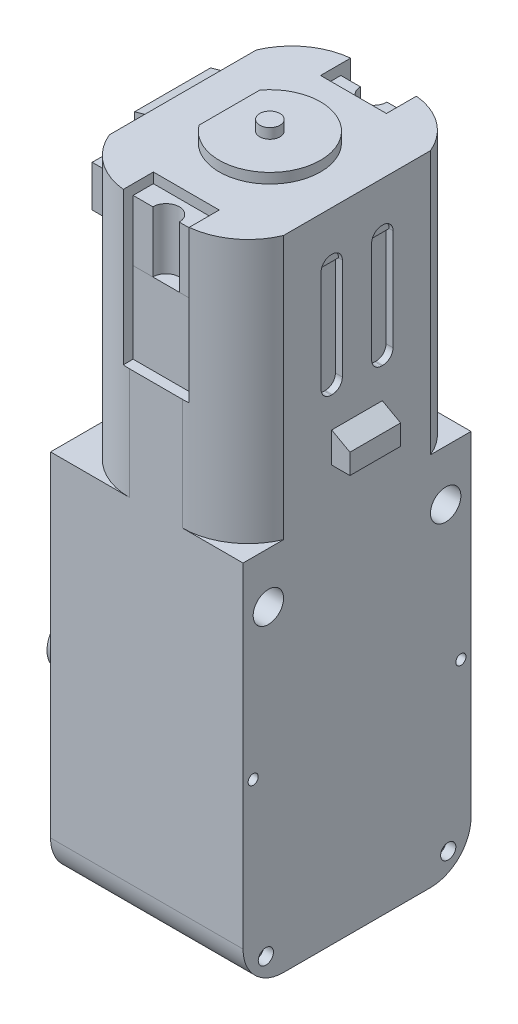
from build123d import *

# Parameters (mm, degrees)
SALIENTE_EXTRUIR2_DEPTH       = 9.5
SALIENTE_EXTRUIR2_DEPTH_BACK  = 9.5
SALIENTE_EXTRUIR4_DEPTH       = 1.3
SALIENTE_EXTRUIR4_DEPTH_BACK  = 1.3
CROQUIS2_R                    = 1.5
CROQUIS3_R                    = 2.5
CORTAR_EXTRUIR1_DEPTH         = 5
CROQUIS5_R                    = 0.75
CROQUIS5_R_2                  = 0.5
CORTAR_EXTRUIR2_DEPTH         = 1
CORTAR_EXTRUIR3_START         = -1
CROQUIS4_R                    = 0.5
CROQUIS4_R_2                  = 0.75
CORTAR_EXTRUIR3_DEPTH         = 1
CROQUIS6_R                    = 2
SALIENTE_EXTRUIR6_DEPTH       = 2
CROQUIS7_R                    = 1.5
CORTAR_EXTRUIR4_DEPTH         = 37.97672376
SALIENTE_EXTRUIR7_DEPTH       = 26
CROQUIS9_W                    = 27.483780483
CROQUIS9_H                    = 31.518144496
CORTAR_EXTRUIR5_DEPTH         = 60.879863894
CORTAR_EXTRUIR7_DEPTH         = 60.879863894
CORTAR_EXTRUIR7_DEPTH_BACK    = 60.879863894
CROQUIS11_W                   = 28.397068188
CROQUIS11_H                   = 15.296763251
CROQUIS12_W                   = 23.354698513
CROQUIS12_H                   = 7.169049234
CROQUIS12_R                   = 1.5
CORTAR_EXTRUIR8_DEPTH         = 60.879863894
CROQUIS14_W                   = 19
CROQUIS14_H                   = 22.5
SALIENTE_EXTRUIR9_DEPTH       = 30
CROQUIS15_R                   = 1.5
CORTAR_EXTRUIR9_DEPTH         = 60.879863894
CROQUIS16_R                   = 2
SALIENTE_EXTRUIR10_DEPTH      = 2
CROQUIS17_R                   = 0.5
CROQUIS17_R_2                 = 0.75
CORTAR_EXTRUIR10_DEPTH        = 60.879863894
CROQUIS20_W                   = 0.773109855
CROQUIS20_H                   = 0.470542453
SALIENTE_EXTRUIR12_DEPTH      = 24
CROQUIS21_W                   = 16.85701041
CROQUIS21_H                   = 22.5
SALIENTE_EXTRUIR13_DEPTH      = 24
CORTAR_EXTRUIR11_DEPTH        = 60.879863894
CROQUIS22_R                   = 2.6
CORTAR_EXTRUIR12_DEPTH        = 5
CROQUIS23_R                   = 2.75
CROQUIS23_R_2                 = 2.6
SALIENTE_EXTRUIR14_DEPTH      = 0.5
SALIENTE_EXTRUIR14_DRAFT      = 8
CROQUIS24_W                   = 2.5
CROQUIS24_H                   = 5
SALIENTE_EXTRUIR15_DEPTH      = 4.7
CROQUIS25_R                   = 1.4
CORTAR_EXTRUIR13_DEPTH        = 4.7
SALIENTE_EXTRUIR17_DEPTH      = 2
SALIENTE_EXTRUIR17_DEPTH_BACK = 19
CROQUIS26_W                   = 3
CROQUIS26_H                   = 5
CORTAR_EXTRUIR14_DEPTH        = 58.938312885
CORTAR_EXTRUIR14_DEPTH_BACK   = 58.938312885
CORTAR_EXTRUIR15_DEPTH        = 60.879863894
CORTAR_EXTRUIR16_START        = -7
CORTAR_EXTRUIR16_DEPTH        = 7
SALIENTE_EXTRUIR18_DEPTH      = 3.75
SALIENTE_EXTRUIR18_DEPTH_BACK = 3.75
CROQUIS30_W                   = 7.5
CROQUIS30_H                   = 1
CORTAR_EXTRUIR17_DEPTH        = 58.938312885
CORTAR_EXTRUIR17_DEPTH_BACK   = 58.938312885
CROQUIS31_W                   = 5.5
CROQUIS31_H                   = 1.5
CORTAR_EXTRUIR18_DEPTH        = 58.938312885
CORTAR_EXTRUIR18_DEPTH_BACK   = 58.938312885
CORTAR_EXTRUIR22_DEPTH        = 59.781677417
CORTAR_EXTRUIR22_DEPTH_BACK   = 59.781677417
CORTAR_EXTRUIR23_START        = -15
CORTAR_EXTRUIR23_DEPTH        = 15
CORTAR_EXTRUIR24_DEPTH        = 5
CROQUIS37_W                   = 15.777972317
CROQUIS37_H                   = 14.808381702
SALIENTE_EXTRUIR19_DEPTH      = 11
CROQUIS38_W                   = 18.88083152
CROQUIS38_H                   = 4.081408477
SALIENTE_EXTRUIR21_DEPTH      = 1
CROQUIS39_W                   = 9.12350037
CROQUIS39_H                   = 4.081408477
SALIENTE_EXTRUIR23_DEPTH      = 0.6
CROQUIS40_W                   = 6.5
CROQUIS40_H                   = 2
SALIENTE_EXTRUIR24_DEPTH      = 8
SALIENTE_EXTRUIR24_2_DEPTH    = 8
CROQUIS41_R                   = 1
SALIENTE_EXTRUIR26_DEPTH      = 7
SALIENTE_EXTRUIR27_DEPTH      = 6
SALIENTE_EXTRUIR27_2_DEPTH    = 6
SALIENTE_EXTRUIR28_DEPTH      = 6
CROQUIS44_W                   = 5.21443522
CROQUIS44_H                   = 9.574781913
SALIENTE_EXTRUIR29_DEPTH      = 2
CROQUIS46_R                   = 0.697640257
SALIENTE_EXTRUIR32_DEPTH      = 0.4
SALIENTE_EXTRUIR32_2_DEPTH    = 0.4
CROQUIS47_R                   = 2.6
SALIENTE_EXTRUIR33_DEPTH      = 14
CORTAR_EXTRUIR25_DEPTH        = 8
CROQUIS49_R                   = 1
CORTAR_EXTRUIR26_DEPTH        = 8


with BuildPart() as part:
    # Croquis1 → Saliente-Extruir2 (new, two sides: drawn at the far end of the back side and taken through both)
    with BuildSketch(Plane.YZ.offset(-SALIENTE_EXTRUIR2_DEPTH_BACK)):
        with BuildLine():
            Line((29.66, 11.25), (-4.84, 11.25))
            ThreePointArc((-4.84, 11.25), (-6.607766953, 10.517766953), (-7.34, 8.75))
            Line((-7.34, 8.75), (-7.34, -8.75))
            ThreePointArc((-7.34, -8.75), (-6.607766953, -10.517766953), (-4.84, -11.25))
            Line((-4.84, -11.25), (29.66, -11.25))
            Line((29.66, -11.25), (29.66, 11.25))
        make_face()
    extrude(amount=SALIENTE_EXTRUIR2_DEPTH + SALIENTE_EXTRUIR2_DEPTH_BACK)

    # Croquis2 → Saliente-Extruir4 (add, two sides: drawn at the far end of the back side and taken through both)
    with BuildSketch(Plane.YZ.offset(-SALIENTE_EXTRUIR4_DEPTH_BACK)):
        Polygon((-11.84, -1.34), (-11.84, -2.5), (-7.34, -2.5), (-7.34, 2.5), (-11.84, 2.5), (-11.84, 1.34), (-11.84, 0), align=None)
        with Locations((-9.34, 0)):
            Circle(CROQUIS2_R, mode=Mode.SUBTRACT)
    extrude(amount=SALIENTE_EXTRUIR4_DEPTH + SALIENTE_EXTRUIR4_DEPTH_BACK)

    # Croquis3 → Cortar-Extruir1 (cut)
    with BuildSketch(Plane(origin=(-9.5, 0, 0), x_dir=(0, -1, 0), z_dir=(-1, 0, 0))):
        Circle(CROQUIS3_R)
    extrude(amount=-CORTAR_EXTRUIR1_DEPTH, mode=Mode.SUBTRACT)

    # Croquis5 → Cortar-Extruir2 (cut)
    with BuildSketch(Plane.YZ.offset(9.5)):
        with Locations((-4.84, 8.75)):
            Circle(CROQUIS5_R)
        with Locations((5.66, 9.75)):
            Circle(CROQUIS5_R_2)
        with Locations((5.66, -9.75)):
            Circle(CROQUIS5_R_2)
        with Locations((-4.84, -8.75)):
            Circle(CROQUIS5_R)
    extrude(amount=-CORTAR_EXTRUIR2_DEPTH, mode=Mode.SUBTRACT)

    # Croquis4 → Cortar-Extruir3 (cut)
    with BuildSketch(Plane.ZY.offset(9.5).offset(CORTAR_EXTRUIR3_START)):
        with Locations((9.75, 5.66)):
            Circle(CROQUIS4_R)
        with Locations((8.75, -4.84)):
            Circle(CROQUIS4_R_2)
        with Locations((-9.75, 5.66)):
            Circle(CROQUIS4_R)
        with Locations((-8.75, -4.84)):
            Circle(CROQUIS4_R_2)
    extrude(amount=CORTAR_EXTRUIR3_DEPTH, mode=Mode.SUBTRACT)

    # Croquis6 → Saliente-Extruir6 (add)
    with BuildSketch(Plane.ZY.offset(9.5)):
        with Locations((0, 10.66)):
            Circle(CROQUIS6_R)
    extrude(amount=SALIENTE_EXTRUIR6_DEPTH)

    # Croquis7 → Cortar-Extruir4 (cut, through all)
    with BuildSketch(Plane.ZY.offset(9.5)):
        with Locations((-8.75, 19.66)):
            Circle(CROQUIS7_R)
        with Locations((8.75, 19.66)):
            Circle(CROQUIS7_R)
    extrude(amount=-CORTAR_EXTRUIR4_DEPTH, mode=Mode.SUBTRACT)

    # Croquis8 → Saliente-Extruir7 (add)
    with BuildSketch(Plane(origin=(0, 29.66, 0), x_dir=(-1, 0, 0), z_dir=(0, 1, 0))):
        with BuildLine():
            Line((1.7, 11.25), (-3.5, 11.25))
            ThreePointArc((-3.5, 11.25), (-7.105551275, 10.158326913), (-9.5, 7.25))
            Line((-9.5, 7.25), (-9.5, -7.25))
            ThreePointArc((-9.5, -7.25), (-7.105551275, -10.158326913), (-3.5, -11.25))
            Line((-3.5, -11.25), (1.7, -11.25))
            ThreePointArc((1.7, -11.25), (5.305551275, -10.158326913), (7.7, -7.25))
            Line((7.7, -7.25), (7.7, 7.25))
            ThreePointArc((7.7, 7.25), (5.305551275, 10.158326913), (1.7, 11.25))
        make_face()
    extrude(amount=SALIENTE_EXTRUIR7_DEPTH)

    # Croquis9 → Cortar-Extruir5 (cut, through all)
    with BuildSketch(Plane(origin=(-9.5, 0, 0), x_dir=(0, -1, 0), z_dir=(-1, 0, 0))):
        with Locations((5.081890242, -0.401551564)):
            Rectangle(CROQUIS9_W, CROQUIS9_H)
    extrude(amount=-CORTAR_EXTRUIR5_DEPTH, mode=Mode.SUBTRACT)

    # Croquis11 → Cortar-Extruir7 (cut, two sides: drawn at the far end of the back side and taken through both)
    with BuildSketch(Plane.ZY.offset(9.5).offset(-CORTAR_EXTRUIR7_DEPTH_BACK)):
        with Locations((-0.835139934, 10.44632309)):
            Rectangle(CROQUIS11_W, CROQUIS11_H)
    extrude(amount=CORTAR_EXTRUIR7_DEPTH + CORTAR_EXTRUIR7_DEPTH_BACK, mode=Mode.SUBTRACT)

    # Croquis12 → Cortar-Extruir8 (cut, through all)
    with BuildSketch(Plane.ZY.offset(9.5)):
        with Locations((0.427349257, 19.075475383)):
            Rectangle(CROQUIS12_W, CROQUIS12_H)
        with Locations((-8.75, 19.66)):
            Circle(CROQUIS12_R, mode=Mode.SUBTRACT)
        with Locations((8.75, 19.66)):
            Circle(CROQUIS12_R, mode=Mode.SUBTRACT)
    extrude(amount=-CORTAR_EXTRUIR8_DEPTH, mode=Mode.SUBTRACT)

    # Croquis14 → Saliente-Extruir9 (add)
    with BuildSketch(Plane(origin=(0, 22.66, 0), x_dir=(-1, 0, 0), z_dir=(0, -1, 0))):
        Rectangle(CROQUIS14_W, CROQUIS14_H)
    extrude(amount=SALIENTE_EXTRUIR9_DEPTH)

    # Croquis15 → Cortar-Extruir9 (cut, through all)
    with BuildSketch(Plane.ZY.offset(9.5)):
        with Locations((-8.75, 24.66)):
            Circle(CROQUIS15_R)
        with Locations((8.75, 24.66)):
            Circle(CROQUIS15_R)
    extrude(amount=-CORTAR_EXTRUIR9_DEPTH, mode=Mode.SUBTRACT)

    # Croquis16 → Saliente-Extruir10 (add)
    with BuildSketch(Plane.ZY.offset(9.5)):
        with Locations((0, 15.66)):
            Circle(CROQUIS16_R)
    extrude(amount=SALIENTE_EXTRUIR10_DEPTH)

    # Croquis17 → Cortar-Extruir10 (cut, through all)
    with BuildSketch(Plane.ZY.offset(9.5)):
        with Locations((10.25, 10.66)):
            Circle(CROQUIS17_R)
        with Locations((9, -5.09)):
            Circle(CROQUIS17_R_2)
        with Locations((-9, -5.09)):
            Circle(CROQUIS17_R_2)
        with Locations((-10.25, 10.66)):
            Circle(CROQUIS17_R)
    extrude(amount=-CORTAR_EXTRUIR10_DEPTH, mode=Mode.SUBTRACT)

    # Croquis20 → Saliente-Extruir12 (add)
    with BuildSketch(Plane.XZ.offset(7.34)):
        with Locations((2.429452283, 4.566914846)):
            Rectangle(CROQUIS20_W, CROQUIS20_H)
    extrude(amount=-SALIENTE_EXTRUIR12_DEPTH)

    # Croquis21 → Saliente-Extruir13 (add)
    with BuildSketch(Plane(origin=(0, -7.34, 0), x_dir=(-1, 0, 0), z_dir=(0, -1, 0))):
        with Locations((-0.10132468, 0)):
            Rectangle(CROQUIS21_W, CROQUIS21_H)
    extrude(amount=-SALIENTE_EXTRUIR13_DEPTH)

    # Croquis19 → Cortar-Extruir11 (cut, through all)
    with BuildSketch(Plane.ZY.offset(9.5)):
        with BuildLine():
            Line((7.25, -7.34), (11.25, -7.34))
            Line((11.25, -7.34), (11.25, -3.34))
            ThreePointArc((11.25, -3.34), (10.078427125, -6.168427125), (7.25, -7.34))
        make_face()
        with BuildLine():
            Line((-11.25, -7.34), (-7.25, -7.34))
            ThreePointArc((-7.25, -7.34), (-10.078427125, -6.168427125), (-11.25, -3.34))
            Line((-11.25, -3.34), (-11.25, -7.34))
        make_face()
    extrude(amount=-CORTAR_EXTRUIR11_DEPTH, mode=Mode.SUBTRACT)

    # Croquis22 → Cortar-Extruir12 (cut)
    with BuildSketch(Plane.ZY.offset(9.5)):
        with Locations((0, 3.86)):
            Circle(CROQUIS22_R)
    extrude(amount=-CORTAR_EXTRUIR12_DEPTH, mode=Mode.SUBTRACT)


with BuildPart() as saliente_extruir14_tool:
    # Croquis23 → Saliente-Extruir14 (with draft: the straight prism first)
    with BuildSketch(Plane.ZY.offset(9.5)):
        with Locations((0, 3.86)):
            Circle(CROQUIS23_R)
        with Locations((0, 3.86)):
            Circle(CROQUIS23_R_2, mode=Mode.SUBTRACT)
    extrude(amount=SALIENTE_EXTRUIR14_DEPTH)
    # Saliente-Extruir14: the draft: its side faces are tilted about the plane it starts from
    saliente_extruir14_sides = [saliente_extruir14_tool.faces().sort_by_distance(p)[0] for p in [
        (-9.75, 3.86, -2.75),
        (-9.75, 3.86, -2.6),
    ]]
    draft(saliente_extruir14_sides, Plane.ZY.offset(9.5), SALIENTE_EXTRUIR14_DRAFT)


with BuildPart() as part_1:
    add(part.part)

    # Saliente-Extruir14: add saliente_extruir14_tool
    add(saliente_extruir14_tool.part)

    # Croquis24 → Saliente-Extruir15 (add)
    with BuildSketch(Plane.XZ.offset(7.34)):
        Rectangle(CROQUIS24_W, CROQUIS24_H)
    extrude(amount=SALIENTE_EXTRUIR15_DEPTH)

    # Croquis25 → Cortar-Extruir13 (cut)
    with BuildSketch(Plane.ZY.offset(1.25)):
        with Locations((0, -9.64)):
            Circle(CROQUIS25_R)
    extrude(amount=-CORTAR_EXTRUIR13_DEPTH, mode=Mode.SUBTRACT)

    # Croquis26 → Saliente-Extruir17 (add, two sides: drawn at the far end of the back side and taken through both)
    with BuildSketch(Plane(origin=(-7.7, 0, 0), x_dir=(0, -1, 0), z_dir=(-1, 0, 0)).offset(-SALIENTE_EXTRUIR17_DEPTH_BACK)):
        with Locations((-35.16, 0)):
            Rectangle(CROQUIS26_W, CROQUIS26_H)
    extrude(amount=SALIENTE_EXTRUIR17_DEPTH + SALIENTE_EXTRUIR17_DEPTH_BACK)

    # Croquis27 → Cortar-Extruir14 (cut, two sides: drawn at the far end of the back side and taken through both)
    with BuildSketch(Plane(origin=(0, 0, 0), x_dir=(0, 1, 0), z_dir=(0, 0, 1)).offset(-CORTAR_EXTRUIR14_DEPTH_BACK)):
        Polygon((36.66, -9.5), (35.66, -11.3), (36.66, -11.3), align=None)
        Polygon((36.66, 9.7), (35.66, 9.7), (36.66, 7.7), align=None)
    extrude(amount=CORTAR_EXTRUIR14_DEPTH + CORTAR_EXTRUIR14_DEPTH_BACK, mode=Mode.SUBTRACT)

    # Croquis28 → Cortar-Extruir15 (cut, through all)
    with BuildSketch(Plane(origin=(-7.7, 0, 0), x_dir=(0, -1, 0), z_dir=(-1, 0, 0))):
        with BuildLine():
            Line((-40.66, -1.446465015), (-45.66, -1.446465015))
            ThreePointArc((-45.66, -1.446465015), (-46.367106781, -1.739358234), (-46.66, -2.446465015))
            Line((-46.66, -2.446465015), (-46.66, -2.553534985))
            ThreePointArc((-46.66, -2.553534985), (-46.367106781, -3.260641766), (-45.66, -3.553534985))
            Line((-45.66, -3.553534985), (-40.66, -3.553534985))
            ThreePointArc((-40.66, -3.553534985), (-39.952893219, -3.260641766), (-39.66, -2.553534985))
            Line((-39.66, -2.553534985), (-39.66, -2.446465015))
            ThreePointArc((-39.66, -2.446465015), (-39.952893219, -1.739358234), (-40.66, -1.446465015))
        make_face()
        with BuildLine():
            Line((-40.66, 3.553534985), (-45.66, 3.553534985))
            ThreePointArc((-45.66, 3.553534985), (-46.367106781, 3.260641766), (-46.66, 2.553534985))
            Line((-46.66, 2.553534985), (-46.66, 2.446465015))
            ThreePointArc((-46.66, 2.446465015), (-46.367106781, 1.739358234), (-45.66, 1.446465015))
            Line((-45.66, 1.446465015), (-40.66, 1.446465015))
            ThreePointArc((-40.66, 1.446465015), (-39.952893219, 1.739358234), (-39.66, 2.446465015))
            Line((-39.66, 2.446465015), (-39.66, 2.553534985))
            ThreePointArc((-39.66, 2.553534985), (-39.952893219, 3.260641766), (-40.66, 3.553534985))
        make_face()
    extrude(amount=-CORTAR_EXTRUIR15_DEPTH, mode=Mode.SUBTRACT)

    # Croquis29 → Cortar-Extruir16 (cut)
    with BuildSketch(Plane.YZ.offset(9.5).offset(CORTAR_EXTRUIR16_START)):
        with BuildLine():
            Line((50.66, -1.446465015), (45.66, -1.446465015))
            ThreePointArc((45.66, -1.446465015), (46.367106781, -1.739358234), (46.66, -2.446465015))
            Line((46.66, -2.446465015), (46.66, -2.553534985))
            ThreePointArc((46.66, -2.553534985), (46.367106781, -3.260641766), (45.66, -3.553534985))
            Line((45.66, -3.553534985), (50.66, -3.553534985))
            ThreePointArc((50.66, -3.553534985), (51.367106781, -3.260641766), (51.66, -2.553534985))
            Line((51.66, -2.553534985), (51.66, -2.446465015))
            ThreePointArc((51.66, -2.446465015), (51.367106781, -1.739358234), (50.66, -1.446465015))
        make_face()
        with BuildLine():
            Line((50.66, 3.553534985), (45.66, 3.553534985))
            ThreePointArc((45.66, 3.553534985), (46.367106781, 3.260641766), (46.66, 2.553534985))
            Line((46.66, 2.553534985), (46.66, 2.446465015))
            ThreePointArc((46.66, 2.446465015), (46.367106781, 1.739358234), (45.66, 1.446465015))
            Line((45.66, 1.446465015), (50.66, 1.446465015))
            ThreePointArc((50.66, 1.446465015), (51.367106781, 1.739358234), (51.66, 2.446465015))
            Line((51.66, 2.446465015), (51.66, 2.553534985))
            ThreePointArc((51.66, 2.553534985), (51.367106781, 3.260641766), (50.66, 3.553534985))
        make_face()
    extrude(amount=CORTAR_EXTRUIR16_DEPTH, mode=Mode.SUBTRACT)

    # Croquis30 → Saliente-Extruir18 (add, two sides: drawn at the far end of the back side and taken through both)
    with BuildSketch(Plane(origin=(0, 0, 0), x_dir=(0, 1, 0), z_dir=(0, 0, 1)).offset(-SALIENTE_EXTRUIR18_DEPTH_BACK)):
        with Locations((51.91, 8.2)):
            Rectangle(CROQUIS30_W, CROQUIS30_H)
    extrude(amount=SALIENTE_EXTRUIR18_DEPTH + SALIENTE_EXTRUIR18_DEPTH_BACK)

    # Croquis31 → Cortar-Extruir17 (cut, two sides: drawn at the far end of the back side and taken through both)
    with BuildSketch(Plane(origin=(0, 0, 0), x_dir=(0, 1, 0), z_dir=(0, 0, 1)).offset(-CORTAR_EXTRUIR17_DEPTH_BACK)):
        with Locations((51.91, 6.95)):
            Rectangle(CROQUIS31_W, CROQUIS31_H)
    extrude(amount=CORTAR_EXTRUIR17_DEPTH + CORTAR_EXTRUIR17_DEPTH_BACK, mode=Mode.SUBTRACT)

    # Croquis32 → Cortar-Extruir18 (cut, two sides: drawn at the far end of the back side and taken through both)
    with BuildSketch(Plane(origin=(0, 0, 0), x_dir=(0, 1, 0), z_dir=(0, 0, 1)).offset(-CORTAR_EXTRUIR18_DEPTH_BACK)):
        Polygon((48.16, 7.7), (48.16, 8.7), (48.926036623, 8.7), align=None)
    extrude(amount=CORTAR_EXTRUIR18_DEPTH + CORTAR_EXTRUIR18_DEPTH_BACK, mode=Mode.SUBTRACT)

    # Croquis33 → Cortar-Extruir22 (cut, two sides: drawn at the far end of the back side and taken through both)
    with BuildSketch(Plane.XY.offset(3.75).offset(-CORTAR_EXTRUIR22_DEPTH_BACK)):
        Polygon((-8.7, 55.386723755), (-7.7, 55.66), (-8.7, 55.66), align=None)
    extrude(amount=CORTAR_EXTRUIR22_DEPTH + CORTAR_EXTRUIR22_DEPTH_BACK, mode=Mode.SUBTRACT)

    # Croquis34 → Cortar-Extruir23 (cut)
    with BuildSketch(Plane(origin=(0, 55.66, 0), x_dir=(1, 0, 0), z_dir=(0, 1, 0)).offset(CORTAR_EXTRUIR23_START)):
        with BuildLine():
            Line((-1.7, -11.25), (3.5, -11.25))
            ThreePointArc((3.5, -11.25), (3.825408038, -11.241849475), (4.15, -11.217418341))
            Line((4.15, -11.217418341), (4.15, -8.25))
            Line((4.15, -8.25), (-2.35, -8.25))
            Line((-2.35, -8.25), (-2.35, -11.217418341))
            ThreePointArc((-2.35, -11.217418341), (-2.025408038, -11.241849475), (-1.7, -11.25))
        make_face()
        with BuildLine():
            ThreePointArc((4.15, 11.217418341), (3.825408038, 11.241849475), (3.5, 11.25))
            Line((3.5, 11.25), (-1.7, 11.25))
            ThreePointArc((-1.7, 11.25), (-2.025408038, 11.241849475), (-2.35, 11.217418341))
            Line((-2.35, 11.217418341), (-2.35, 8.25))
            Line((-2.35, 8.25), (4.15, 8.25))
            Line((4.15, 8.25), (4.15, 11.217418341))
        make_face()
    extrude(amount=CORTAR_EXTRUIR23_DEPTH, mode=Mode.SUBTRACT)

    # Croquis35 → Cortar-Extruir24 (cut)
    with BuildSketch(Plane(origin=(0, 55.66, 0), x_dir=(-1, 0, 0), z_dir=(0, 1, 0))):
        with BuildLine():
            ThreePointArc((3.1, 3), (-5.9, 0), (3.1, -3))
            Line((3.1, -3), (3.1, 3))
        make_face()
    extrude(amount=-CORTAR_EXTRUIR24_DEPTH, mode=Mode.SUBTRACT)


with BuildPart() as body_2:
    # Croquis37 → Saliente-Extruir19 (new body)
    with BuildSketch(Plane(origin=(0, 39.66, 0), x_dir=(1, 0, 0), z_dir=(0, 1, 0))):
        with Locations((0.922815991, 0.584105791)):
            Rectangle(CROQUIS37_W, CROQUIS37_H)
    extrude(amount=SALIENTE_EXTRUIR19_DEPTH)


with BuildPart() as body_3:
    # Croquis38 → Saliente-Extruir21 (new body)
    with BuildSketch(Plane.ZY.offset(6.2)):
        with Locations((0, 52.619295761)):
            Rectangle(CROQUIS38_W, CROQUIS38_H)
    extrude(amount=SALIENTE_EXTRUIR21_DEPTH)


with BuildPart() as body_4:
    # Croquis39 → Saliente-Extruir23 (new body)
    with BuildSketch(Plane.ZY.offset(7.2)):
        with Locations((-0.017583208, 52.619295761)):
            Rectangle(CROQUIS39_W, CROQUIS39_H)
    extrude(amount=SALIENTE_EXTRUIR23_DEPTH)


with BuildPart() as body_5:
    # Croquis40 → Saliente-Extruir24 (new body)
    with BuildSketch(Plane(origin=(0, 40.66, 0), x_dir=(-1, 0, 0), z_dir=(0, 1, 0))):
        with Locations((-0.9, -9.25)):
            Rectangle(CROQUIS40_W, CROQUIS40_H)
    extrude(amount=SALIENTE_EXTRUIR24_DEPTH)


with BuildPart() as body_6:
    # Croquis40 → Saliente-Extruir24 2 (new body)
    with BuildSketch(Plane(origin=(0, 40.66, 0), x_dir=(-1, 0, 0), z_dir=(0, 1, 0))):
        with Locations((-0.9, 9.25)):
            Rectangle(CROQUIS40_W, CROQUIS40_H)
    extrude(amount=SALIENTE_EXTRUIR24_2_DEPTH)


with BuildPart() as body_7:
    # Croquis41 → Saliente-Extruir26 (new body)
    with BuildSketch(Plane(origin=(0, 50.66, 0), x_dir=(1, 0, 0), z_dir=(0, 1, 0))):
        with Locations((0.9, 0)):
            Circle(CROQUIS41_R)
    extrude(amount=SALIENTE_EXTRUIR26_DEPTH)


with BuildPart() as body_8:
    # Croquis42 → Saliente-Extruir27 (new body)
    with BuildSketch(Plane(origin=(0, 48.66, 0), x_dir=(1, 0, 0), z_dir=(0, 1, 0))):
        with BuildLine():
            Line((4.15, -8.25), (-2.35, -8.25))
            Line((-2.35, -8.25), (-2.35, -10.25))
            Line((-2.35, -10.25), (-0.405896925, -10.25))
            ThreePointArc((-0.405896925, -10.25), (0.9, -8.944103075), (2.205896925, -10.25))
            Line((2.205896925, -10.25), (4.15, -10.25))
            Line((4.15, -10.25), (4.15, -8.25))
        make_face()
    extrude(amount=SALIENTE_EXTRUIR27_DEPTH)


with BuildPart() as body_9:
    # Croquis42 → Saliente-Extruir27 2 (new body)
    with BuildSketch(Plane(origin=(0, 48.66, 0), x_dir=(1, 0, 0), z_dir=(0, 1, 0))):
        with BuildLine():
            Line((4.15, 10.25), (2.205896925, 10.25))
            ThreePointArc((2.205896925, 10.25), (0.9, 8.944103075), (-0.405896925, 10.25))
            Line((-0.405896925, 10.25), (-2.35, 10.25))
            Line((-2.35, 10.25), (-2.35, 8.25))
            Line((-2.35, 8.25), (4.15, 8.25))
            Line((4.15, 8.25), (4.15, 10.25))
        make_face()
    extrude(amount=SALIENTE_EXTRUIR27_2_DEPTH)


with BuildPart() as body_10:
    # Croquis43 → Saliente-Extruir28 (new body)
    with BuildSketch(Plane(origin=(0, 50.66, 0), x_dir=(1, 0, 0), z_dir=(0, 1, 0))):
        with BuildLine():
            Line((-3.1, -3), (-3.1, 3))
            ThreePointArc((-3.1, 3), (5.9, 0), (-3.1, -3))
        make_face()
    extrude(amount=SALIENTE_EXTRUIR28_DEPTH)


with BuildPart() as body_11:
    # Croquis44 → Saliente-Extruir29 (new body)
    with BuildSketch(Plane(origin=(0, 50.66, 0), x_dir=(1, 0, 0), z_dir=(0, 1, 0))):
        with Locations((6.50794808, -0.067428042)):
            Rectangle(CROQUIS44_W, CROQUIS44_H)
    extrude(amount=SALIENTE_EXTRUIR29_DEPTH)


with BuildPart() as body_12:
    # Croquis46 → Saliente-Extruir32 (new body)
    with BuildSketch(Plane.ZY.offset(7.2)):
        with BuildLine():
            Line((8.197491621, 52.459588978), (8.197491621, 52.779002545))
            ThreePointArc((8.197491621, 52.779002545), (7.904598402, 53.486109326), (7.197491621, 53.779002545))
            Line((7.197491621, 53.779002545), (4.544166977, 53.779002545))
            Line((4.544166977, 53.779002545), (4.544166977, 51.459588978))
            Line((4.544166977, 51.459588978), (7.197491621, 51.459588978))
            ThreePointArc((7.197491621, 51.459588978), (7.904598402, 51.752482197), (8.197491621, 52.459588978))
        make_face()
        with Locations((7.197491621, 52.619295761)):
            Circle(CROQUIS46_R, mode=Mode.SUBTRACT)
    extrude(amount=SALIENTE_EXTRUIR32_DEPTH)


with BuildPart() as body_13:
    # Croquis46 → Saliente-Extruir32 2 (new body)
    with BuildSketch(Plane.ZY.offset(7.2)):
        with BuildLine():
            ThreePointArc((-7.197491621, 53.779002545), (-7.904598402, 53.486109326), (-8.197491621, 52.779002545))
            Line((-8.197491621, 52.779002545), (-8.197491621, 52.459588978))
            ThreePointArc((-8.197491621, 52.459588978), (-7.904598402, 51.752482197), (-7.197491621, 51.459588978))
            Line((-7.197491621, 51.459588978), (-4.544166977, 51.459588978))
            Line((-4.544166977, 51.459588978), (-4.544166977, 53.779002545))
            Line((-4.544166977, 53.779002545), (-7.197491621, 53.779002545))
        make_face()
        with Locations((-7.197491621, 52.619295761)):
            Circle(CROQUIS46_R, mode=Mode.SUBTRACT)
    extrude(amount=SALIENTE_EXTRUIR32_2_DEPTH)


with BuildPart() as body_14:
    # Croquis47 → Saliente-Extruir33 (new body)
    with BuildSketch(Plane.ZY.offset(4.5)):
        with Locations((0, 3.86)):
            Circle(CROQUIS47_R)
    extrude(amount=SALIENTE_EXTRUIR33_DEPTH)

    # Croquis48 → Cortar-Extruir25 (cut)
    with BuildSketch(Plane.ZY.offset(18.5)):
        with BuildLine():
            Line((-1.922888452, 5.61), (1.922888452, 5.61))
            ThreePointArc((1.922888452, 5.61), (0, 6.46), (-1.922888452, 5.61))
        make_face()
        with BuildLine():
            Line((1.922888452, 2.11), (-1.922888452, 2.11))
            ThreePointArc((-1.922888452, 2.11), (0, 1.26), (1.922888452, 2.11))
        make_face()
    extrude(amount=-CORTAR_EXTRUIR25_DEPTH, mode=Mode.SUBTRACT)

    # Croquis49 → Cortar-Extruir26 (cut)
    with BuildSketch(Plane.ZY.offset(18.5)):
        with Locations((0, 3.86)):
            Circle(CROQUIS49_R)
    extrude(amount=-CORTAR_EXTRUIR26_DEPTH, mode=Mode.SUBTRACT)


solid = Compound([part_1.part, body_2.part, body_3.part, body_4.part, body_5.part, body_6.part, body_7.part, body_8.part, body_9.part, body_10.part, body_11.part, body_12.part, body_13.part, body_14.part])
